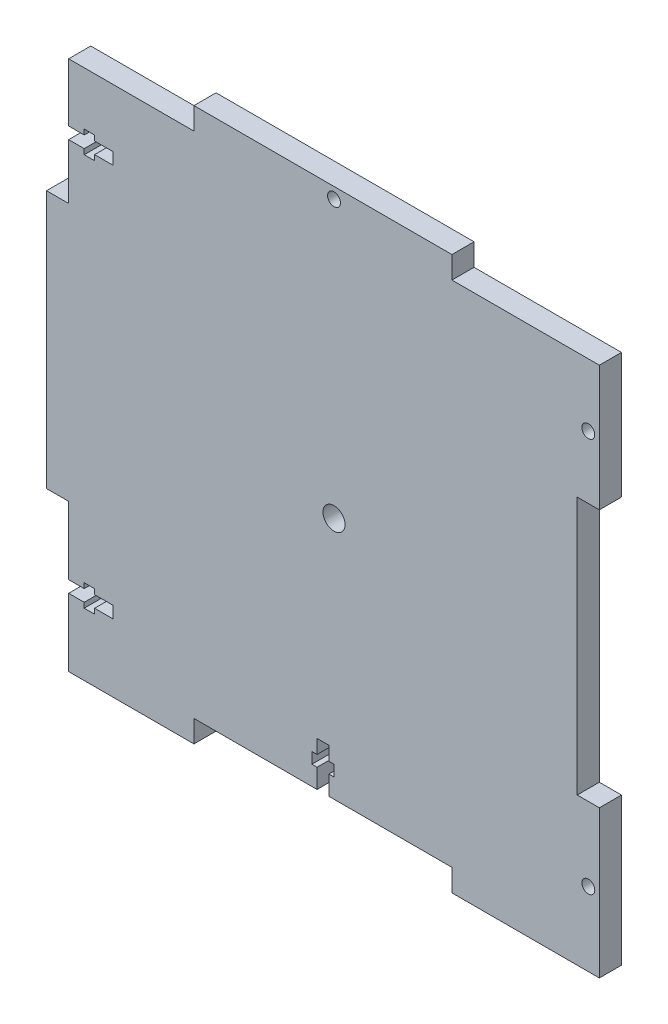
from build123d import *

# Parameters (mm, degrees)
SKETCH1_R           = 1.75
SKETCH1_R_2         = 3
BOSS_EXTRUDE2_DEPTH = 6


with BuildPart() as part:
    # Sketch1 → Boss-Extrude2 (new body)
    with BuildSketch(Plane.XY):
        Polygon((72, 72), (32, 72), (32, 78), (-38, 78), (-38, 72), (-72, 72), (-72, 56.2), (-67.772810154, 56.2), (-67.772810154, 57.6), (-64.957983727, 57.6), (-64.957983727, 56.2), (-60, 56.2), (-60, 53), (-64.957983727, 53), (-64.957983727, 51.568504207), (-67.772810154, 51.568504207), (-67.772810154, 53), (-72, 53), (-72, 38), (-78, 38), (-78, -32), (-72, -32), (-72, -50.4), (-67.78187279, -50.4), (-67.78187279, -49), (-64.967046362, -49), (-64.967046362, -50.4), (-60, -50.4), (-60, -53.6), (-64.967046362, -53.6), (-64.967046362, -55), (-67.78187279, -55), (-67.78187279, -53.6), (-72, -53.6), (-72, -72), (-38, -72), (-38, -66), (-4.6, -66), (-4.6, -60.77149924), (-6, -60.77149924), (-6, -57.77149924), (-4.6, -57.77149924), (-4.6, -54), (-1.4, -54), (-1.4, -57.77149924), (0, -57.77149924), (0, -60.77149924), (-1.4, -60.77149924), (-1.4, -66), (32, -66), (32, -72), (72, -72), (72, -32), (66, -32), (66, 38), (72, 38), align=None)
        with Locations((69, -52)):
            Circle(SKETCH1_R, mode=Mode.SUBTRACT)
        Circle(SKETCH1_R_2, mode=Mode.SUBTRACT)
        with Locations((69, 55)):
            Circle(SKETCH1_R, mode=Mode.SUBTRACT)
        with Locations((0, 75)):
            Circle(SKETCH1_R, mode=Mode.SUBTRACT)
    extrude(amount=BOSS_EXTRUDE2_DEPTH)


solid = part.part
